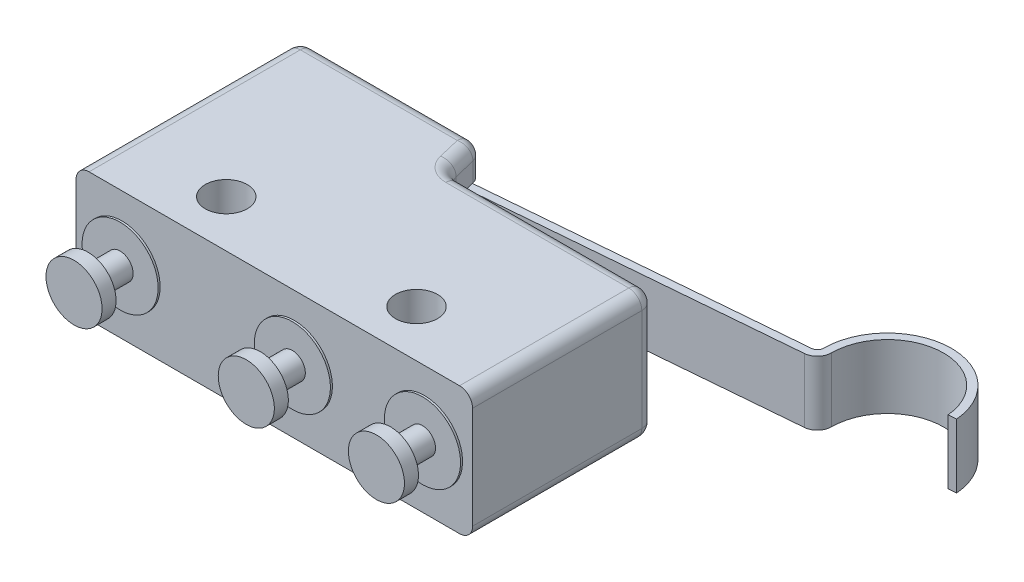
from build123d import *

# Parameters (mm, degrees)
BOSS_EXTRUDE1_DEPTH = 3.2
SKETCH3_R           = 1.05
CUT_EXTRUDE1_DEPTH  = 16.4
EXTRUDE_THIN1_DEPTH = 1.6
FILLET1_R           = 0.65
SKETCH5_W           = 13.579197801
SKETCH5_H           = 3.2
CUT_EXTRUDE2_DEPTH  = 16.4
FILLET2_R           = 0.3
FILLET3_R           = 0.7
LPATTERN1_COUNT     = 2
LPATTERN1_PITCH     = 15.1
LPATTERN2_COUNT     = 2
LPATTERN2_PITCH     = 8.6


with BuildPart() as part:
    # Sketch2 → Boss-Extrude1 (new, symmetric)
    with BuildSketch(Plane(origin=(0, 0, 0), x_dir=(1, 0, 0), z_dir=(0, 1, 0))):
        Polygon((0, 0), (19.8, 0), (19.8, 9.1), (9.5, 9.1), (9, 11.2), (0, 11.2), align=None)
    extrude(amount=BOSS_EXTRUDE1_DEPTH, both=True)

    # Sketch3 → Cut-Extrude1 (cut)
    with BuildSketch(Plane(origin=(0, 3.2, 0), x_dir=(1, 0, 0), z_dir=(0, 1, 0))):
        with Locations((5.15, 2.35)):
            Circle(SKETCH3_R)
        with Locations((14.65, 2.35)):
            Circle(SKETCH3_R)
    extrude(amount=-CUT_EXTRUDE1_DEPTH, mode=Mode.SUBTRACT)

    # Sketch4 → Extrude-Thin1 (add, symmetric)
    with BuildSketch(Plane(origin=(0, 0, 0), x_dir=(1, 0, 0), z_dir=(0, 1, 0))):
        with BuildLine():
            Line((1.292236799, 10.001697091), (25.025910468, 12.027810166))
            ThreePointArc((25.025910468, 12.027810166), (27.942123478, 15.488402844), (31.402716155, 12.572189834))
            Line((31.402716155, 12.572189834), (31.0041658, 12.538166105))
            ThreePointArc((31.0041658, 12.538166105), (27.776970564, 15.065633982), (25.487099181, 11.665726334))
            Line((25.487099181, 11.665726334), (1.326260528, 9.603146736))
            Line((1.326260528, 9.603146736), (1.292236799, 10.001697091))
        make_face()
    extrude(amount=EXTRUDE_THIN1_DEPTH, both=True)

    # Fillet1
    fillet1_edges = [part.edges().sort_by_distance(p)[0] for p in [
        (0, 0, -11.2),
        (0, 3.2, -5.6),
        (0, -3.2, -5.6),
        (9.25, -3.2, -10.15),
        (9, 0, -11.2),
        (14.65, -3.2, -9.1),
        (19.8, -3.2, -4.55),
        (9.5, 0, -9.1),
        (19.8, 0, -9.1),
        (19.8, 3.2, -4.55),
        (14.65, 3.2, -9.1),
        (9.25, 3.2, -10.15),
        (4.5, -3.2, -11.2),
        (4.5, 3.2, -11.2),
    ]]
    fillet(fillet1_edges, radius=FILLET1_R)

    # Sketch5 → Cut-Extrude2 (cut)
    with BuildSketch(Plane(origin=(-0.838304969, 0, -9.819815492), x_dir=(-0.9963758886901375, 0, 0.08505932304538345), z_dir=(-0.08505932304538345, 0, -0.9963758886901375))):
        with Locations((-4.790866227, 0)):
            Rectangle(SKETCH5_W, SKETCH5_H)
    extrude(amount=CUT_EXTRUDE2_DEPTH, mode=Mode.SUBTRACT)

    # Fillet2
    fillet2_edges = [part.edges().sort_by_distance(p)[0] for p in [
        (25.025910468, 0, -12.027810166),
    ]]
    fillet(fillet2_edges, radius=FILLET2_R)

    # Fillet3
    fillet3_edges = [part.edges().sort_by_distance(p)[0] for p in [
        (25.487099181, 0, -11.665726334),
    ]]
    fillet(fillet3_edges, radius=FILLET3_R)

    # Sketch6 → Revolve1 (revolve)
    with BuildSketch(Plane(origin=(0, 0, 0), x_dir=(1, 0, 0), z_dir=(0, 1, 0))):
        Polygon((2.3, 0.658981297), (2.3, -2.4), (3.7, -2.4), (3.7, -1.7), (2.95, -1.7), (2.95, -0.1), (4.2, -0.1), (4.2, 0.658981297), align=None)
    revolve1 = revolve(axis=Axis((2.3, 0, -0.658981297), (0, 0, 1)))

    # LPattern1: Revolve1 ×2
    with Locations(*[(i * LPATTERN1_PITCH, 0, 0) for i in range(1, LPATTERN1_COUNT)]):
        add(revolve1)

    # LPattern2: Revolve1 ×2
    with Locations(*[(i * LPATTERN2_PITCH, 0, 0) for i in range(1, LPATTERN2_COUNT)]):
        add(revolve1)


solid = part.part
